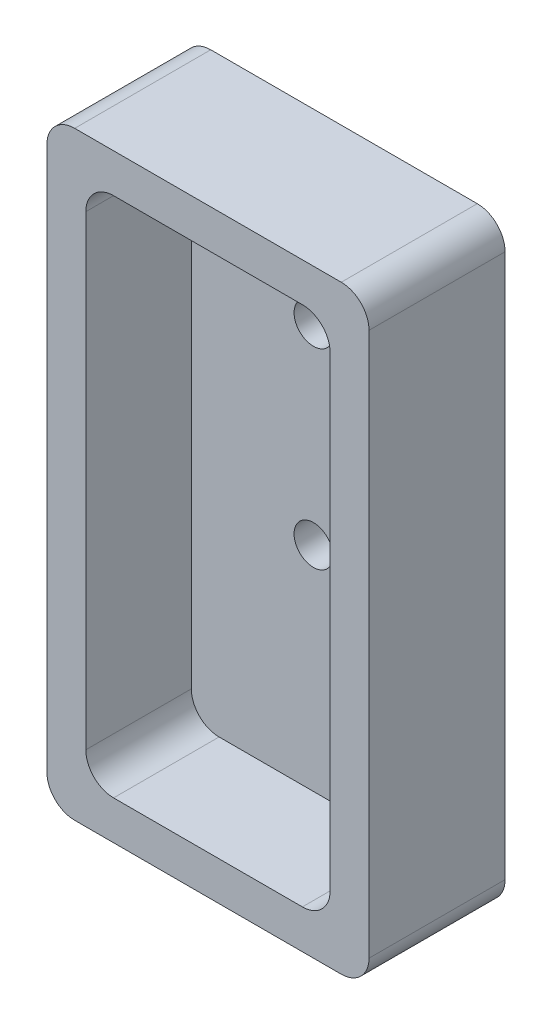
from build123d import *

# Parameters (mm, degrees)
ESBO_O1_W                  = 58
ESBO_O1_H                  = 24.5
RESSALTO_EXTRUS_O1_DEPTH   = 107.92
FILETE1_R                  = 5
ESBO_O2_W                  = 44
ESBO_O2_H                  = 93.92
CORTE_EXTRUS_O1_DEPTH      = 19
FILETE2_R                  = 5
ESBO_O3_R                  = 3.5
CORTE_EXTRUS_O2_DEPTH      = 20
CORTE_EXTRUS_O2_DEPTH_BACK = 6.5


with BuildPart() as part:
    # Esboço1 → Ressalto-extrusão1 (new body)
    with BuildSketch(Plane(origin=(0, 0, 0), x_dir=(1, 0, 0), z_dir=(0, 1, 0))):
        Rectangle(ESBO_O1_W, ESBO_O1_H)
    extrude(amount=RESSALTO_EXTRUS_O1_DEPTH)

    # Filete1
    filete1_edges = [part.edges().sort_by_distance(p)[0] for p in [
        (29, 107.92, 0),
        (-29, 107.92, 0),
        (29, 0, 0),
        (-29, 0, 0),
    ]]
    fillet(filete1_edges, radius=FILETE1_R)

    # Esboço2 → Corte-extrusão1 (cut)
    with BuildSketch(Plane.XY.offset(12.25)):
        with Locations((0, 53.96)):
            Rectangle(ESBO_O2_W, ESBO_O2_H)
    extrude(amount=-CORTE_EXTRUS_O1_DEPTH, mode=Mode.SUBTRACT)

    # Filete2
    filete2_edges = [part.edges().sort_by_distance(p)[0] for p in [
        (-22, 7, 2.75),
        (-22, 100.92, 2.75),
        (22, 100.92, 2.75),
        (22, 7, 2.75),
    ]]
    fillet(filete2_edges, radius=FILETE2_R)

    # Esboço3 → Corte-extrusão2 (cut, two sides)
    with BuildSketch(Plane.XY.offset(-6.75)) as corte_extrus_o2_sk:
        with Locations((0, 79.92)):
            Circle(ESBO_O3_R)
        with Locations((0, 45.4387)):
            Circle(ESBO_O3_R)
    extrude(amount=CORTE_EXTRUS_O2_DEPTH, mode=Mode.SUBTRACT)
    extrude(corte_extrus_o2_sk.sketch, amount=-CORTE_EXTRUS_O2_DEPTH_BACK, mode=Mode.SUBTRACT)


solid = part.part
